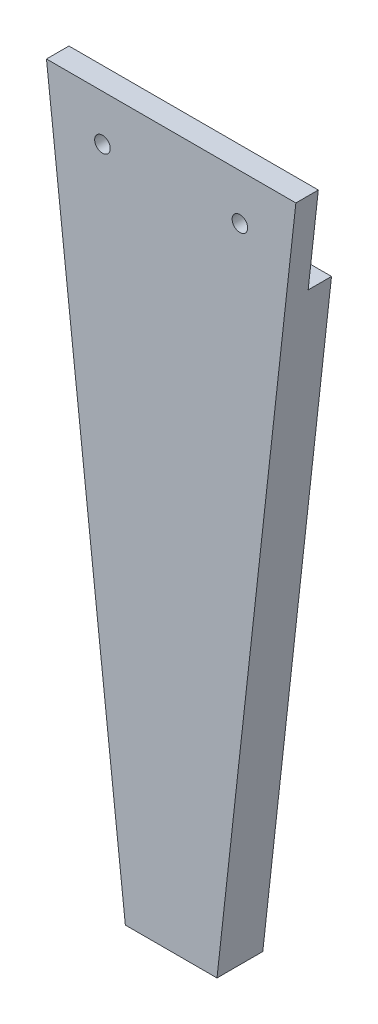
from build123d import *

# Parameters (mm, degrees)
BOSS_EXTRUDE1_DEPTH = 10
CUT_EXTRUDE1_DEPTH  = 5.1
SKETCH2_R           = 1.7
CUT_EXTRUDE2_DEPTH  = 5.1


with BuildPart() as part:
    # Sketch1 → Boss-Extrude1 (new body)
    with BuildSketch(Plane.XY):
        Polygon((-27.22, 20), (-10, -135.135135135), (10, -135.135135135), (27.22, 20), align=None)
    extrude(amount=BOSS_EXTRUDE1_DEPTH)

    # Sketch1_3 → Cut-Extrude1 (cut)
    with BuildSketch(Plane.XY):
        Polygon((-27.22, 20), (-25, 0), (25, 0), (27.22, 20), align=None)
    extrude(amount=CUT_EXTRUDE1_DEPTH, mode=Mode.SUBTRACT)

    # Sketch2 → Cut-Extrude2 (cut)
    with BuildSketch(Plane(origin=(0, 0, 5.1), x_dir=(-1, 0, 0), z_dir=(0, 0, -1))):
        with Locations((-15, 10)):
            Circle(SKETCH2_R)
        with Locations((15, 10)):
            Circle(SKETCH2_R)
    extrude(amount=-CUT_EXTRUDE2_DEPTH, mode=Mode.SUBTRACT)


solid = part.part
